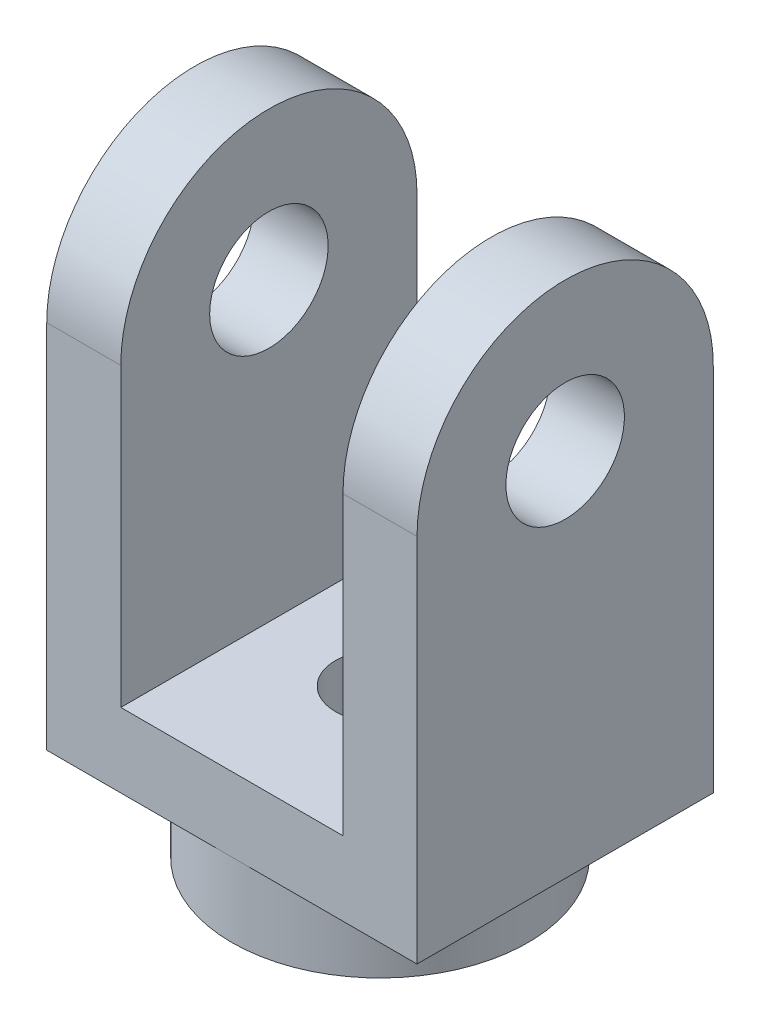
from build123d import *

# Parameters (mm, degrees)
SKETCH1_R               = 50
SKETCH1_R_2             = 37.5
BOSS_EXTRUDE3_DEPTH     = 25
SKETCH2_R               = 37.5
BOSS_EXTRUDE4_DEPTH     = 25
SKETCH3_W               = 125
SKETCH3_H               = 100
BOSS_EXTRUDE5_DEPTH     = 25
SKETCH4_W               = 25
SKETCH4_H               = 100
BOSS_EXTRUDE6_DEPTH     = 100
SKETCH5_W               = 25
SKETCH5_H               = 100
BOSS_EXTRUDE7_DEPTH     = 100
SKETCH7_R               = 15
CUT_EXTRUDE1_DEPTH      = 101
CUT_EXTRUDE1_DEPTH_BACK = 51
BOSS_EXTRUDE12_DEPTH    = 25
BOSS_EXTRUDE13_DEPTH    = 25
SKETCH14_R              = 20
CUT_EXTRUDE2_DEPTH      = 1
CUT_EXTRUDE2_DEPTH_BACK = 126


with BuildPart() as part:
    # Sketch1 → Boss-Extrude3 (new body)
    with BuildSketch(Plane(origin=(0, 0, 0), x_dir=(1, 0, 0), z_dir=(0, 1, 0))):
        Circle(SKETCH1_R)
        Circle(SKETCH1_R_2, mode=Mode.SUBTRACT)
    extrude(amount=BOSS_EXTRUDE3_DEPTH)

    # Sketch2 → Boss-Extrude4 (add)
    with BuildSketch(Plane.XZ):
        Circle(SKETCH2_R)
    extrude(amount=-BOSS_EXTRUDE4_DEPTH)

    # Sketch3 → Boss-Extrude5 (add)
    with BuildSketch(Plane(origin=(0, 25, 0), x_dir=(1, 0, 0), z_dir=(0, 1, 0))):
        Rectangle(SKETCH3_W, SKETCH3_H)
    extrude(amount=BOSS_EXTRUDE5_DEPTH)

    # Sketch4 → Boss-Extrude6 (add)
    with BuildSketch(Plane(origin=(0, 50, 0), x_dir=(1, 0, 0), z_dir=(0, 1, 0))):
        with Locations((-50, 0)):
            Rectangle(SKETCH4_W, SKETCH4_H)
    extrude(amount=BOSS_EXTRUDE6_DEPTH)

    # Sketch5 → Boss-Extrude7 (add)
    with BuildSketch(Plane(origin=(0, 50, 0), x_dir=(1, 0, 0), z_dir=(0, 1, 0))):
        with Locations((50, 0)):
            Rectangle(SKETCH5_W, SKETCH5_H)
    extrude(amount=BOSS_EXTRUDE7_DEPTH)

    # Sketch7 → Cut-Extrude1 (cut, two sides)
    with BuildSketch(Plane(origin=(0, 50, 0), x_dir=(1, 0, 0), z_dir=(0, 1, 0))) as cut_extrude1_sk:
        Circle(SKETCH7_R)
    extrude(amount=CUT_EXTRUDE1_DEPTH, mode=Mode.SUBTRACT)
    extrude(cut_extrude1_sk.sketch, amount=-CUT_EXTRUDE1_DEPTH_BACK, mode=Mode.SUBTRACT)

    # Sketch11 → Boss-Extrude12 (add)
    with BuildSketch(Plane(origin=(62.5, 0, 0), x_dir=(0, 0, -1), z_dir=(1, 0, 0))):
        with BuildLine():
            Line((-50, 25), (50, 25))
            Line((50, 25), (50, 150))
            ThreePointArc((50, 150), (0, 200), (-50, 150))
            Line((-50, 150), (-50, 25))
        make_face()
    extrude(amount=-BOSS_EXTRUDE12_DEPTH)

    # Sketch13 → Boss-Extrude13 (add)
    with BuildSketch(Plane.ZY.offset(62.5)):
        with BuildLine():
            Line((50, 150), (-50, 150))
            ThreePointArc((-50, 150), (0, 200), (50, 150))
        make_face()
    extrude(amount=-BOSS_EXTRUDE13_DEPTH)

    # Sketch14 → Cut-Extrude2 (cut, two sides)
    with BuildSketch(Plane.ZY.offset(62.5)) as cut_extrude2_sk:
        with Locations((0, 150)):
            Circle(SKETCH14_R)
    extrude(amount=CUT_EXTRUDE2_DEPTH, mode=Mode.SUBTRACT)
    extrude(cut_extrude2_sk.sketch, amount=-CUT_EXTRUDE2_DEPTH_BACK, mode=Mode.SUBTRACT)


solid = part.part
